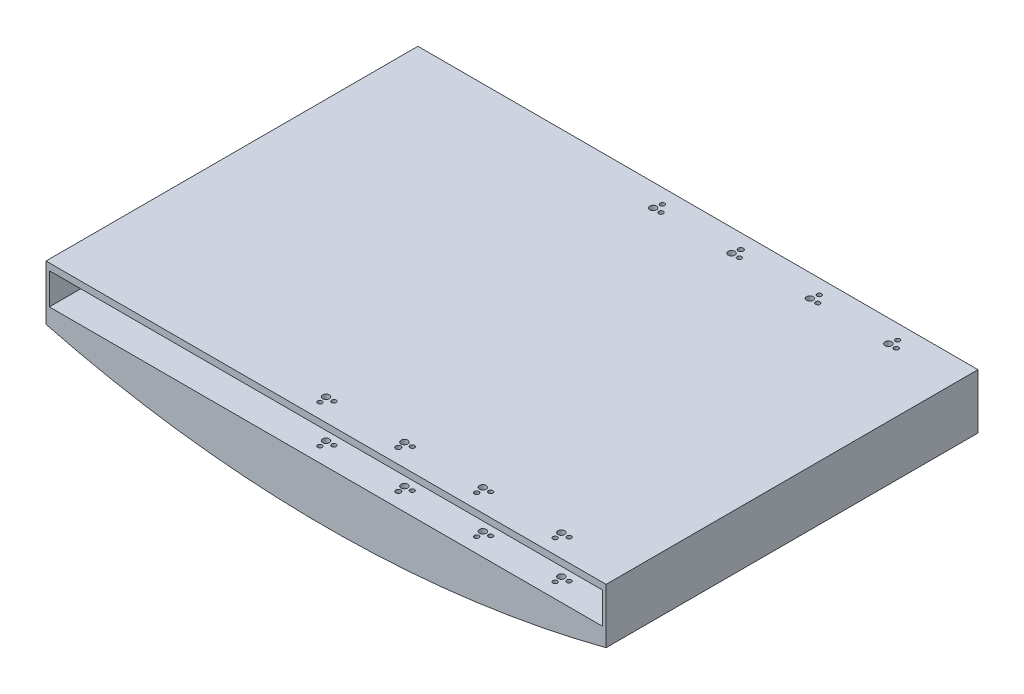
from build123d import *

# Parameters (mm, degrees)
SKETCH1_W               = 494
SKETCH1_H               = 33
BOSS_EXTRUDE2_DEPTH     = 166
SKETCH6_W               = 494
SKETCH6_H               = 32.558092213
CUT_EXTRUDE2_DEPTH      = 156
SKETCH8_W               = 494
SKETCH8_H               = 30
BOSS_EXTRUDE3_DEPTH     = 2.5
SKETCH9_W               = 494
SKETCH9_H               = 30
BOSS_EXTRUDE4_DEPTH     = 2.5
SKETCH10_W              = 494
SKETCH10_H              = 30
BOSS_EXTRUDE5_DEPTH     = 2.5
SKETCH11_W              = 494
SKETCH11_H              = 30
BOSS_EXTRUDE6_DEPTH     = 2.5
SKETCH7_R               = 3
SKETCH7_R_2             = 2
SKETCH7_R_3             = 2.270552225
CUT_EXTRUDE3_DEPTH      = 1
CUT_EXTRUDE3_DEPTH_BACK = 81.774674129


with BuildPart() as part:
    # Sketch1 → Boss-Extrude2 (new body, symmetric)
    with BuildSketch(Plane.XY):
        with BuildLine():
            Line((0, 0), (0, 49))
            Line((0, 49), (500, 49))
            Line((500, 49), (500, 0))
            ThreePointArc((500, 0), (250, -31.774674129), (0, 0))
        make_face()
        with Locations((250, 29)):
            Rectangle(SKETCH1_W, SKETCH1_H, mode=Mode.SUBTRACT)
    extrude(amount=BOSS_EXTRUDE2_DEPTH, both=True)

    # Sketch6 → Cut-Extrude2 (cut, symmetric)
    with BuildSketch(Plane.XY):
        with Locations((250, -16.279046107)):
            Rectangle(SKETCH6_W, SKETCH6_H)
    extrude(amount=CUT_EXTRUDE2_DEPTH, both=True, mode=Mode.SUBTRACT)

    # Sketch8 → Boss-Extrude3 (add)
    with BuildSketch(Plane(origin=(0, 12.5, 0), x_dir=(1, 0, 0), z_dir=(0, 1, 0))):
        with Locations((250, -151)):
            Rectangle(SKETCH8_W, SKETCH8_H)
    extrude(amount=BOSS_EXTRUDE3_DEPTH)

    # Sketch9 → Boss-Extrude4 (add)
    with BuildSketch(Plane.XZ.offset(-45.5)):
        with Locations((250, 151)):
            Rectangle(SKETCH9_W, SKETCH9_H)
    extrude(amount=BOSS_EXTRUDE4_DEPTH)

    # Sketch10 → Boss-Extrude5 (add)
    with BuildSketch(Plane.XZ.offset(-45.5)):
        with Locations((250, -151)):
            Rectangle(SKETCH10_W, SKETCH10_H)
    extrude(amount=BOSS_EXTRUDE5_DEPTH)

    # Sketch11 → Boss-Extrude6 (add)
    with BuildSketch(Plane(origin=(0, 12.5, 0), x_dir=(1, 0, 0), z_dir=(0, 1, 0))):
        with Locations((250, 151)):
            Rectangle(SKETCH11_W, SKETCH11_H)
    extrude(amount=BOSS_EXTRUDE6_DEPTH)

    # Sketch7 → Cut-Extrude3 (cut, two sides)
    with BuildSketch(Plane(origin=(0, 49, 0), x_dir=(1, 0, 0), z_dir=(0, 1, 0))) as cut_extrude3_sk:
        with Locations((230, -146)):
            Circle(SKETCH7_R)
        with Locations((300, -146)):
            Circle(SKETCH7_R)
        with Locations((370, -146)):
            Circle(SKETCH7_R)
        with Locations((440, -146)):
            Circle(SKETCH7_R)
        with Locations((231.366830489, -152.86525851)):
            Circle(SKETCH7_R_2)
        with Locations((301.366830489, -152.86525851)):
            Circle(SKETCH7_R_3)
        with Locations((371.366830489, -152.86525851)):
            Circle(SKETCH7_R_2)
        with Locations((441.366830489, -152.86525851)):
            Circle(SKETCH7_R_2)
        with Locations((237, -146)):
            Circle(SKETCH7_R_2)
        with Locations((307, -146)):
            Circle(SKETCH7_R_2)
        with Locations((377, -146)):
            Circle(SKETCH7_R_2)
        with Locations((447, -146)):
            Circle(SKETCH7_R_2)
        with Locations((440, 146)):
            Circle(SKETCH7_R)
        with Locations((370, 146)):
            Circle(SKETCH7_R)
        with Locations((300, 146)):
            Circle(SKETCH7_R)
        with Locations((230, 146)):
            Circle(SKETCH7_R)
        with Locations((441.366830489, 152.86525851)):
            Circle(SKETCH7_R_2)
        with Locations((447, 146)):
            Circle(SKETCH7_R_2)
        with Locations((371.366830489, 152.86525851)):
            Circle(SKETCH7_R_2)
        with Locations((377, 146)):
            Circle(SKETCH7_R_2)
        with Locations((307, 146)):
            Circle(SKETCH7_R_2)
        with Locations((301.366830489, 152.86525851)):
            Circle(SKETCH7_R_3)
        with Locations((237, 146)):
            Circle(SKETCH7_R_2)
        with Locations((231.366830489, 152.86525851)):
            Circle(SKETCH7_R_2)
    extrude(amount=CUT_EXTRUDE3_DEPTH, mode=Mode.SUBTRACT)
    extrude(cut_extrude3_sk.sketch, amount=-CUT_EXTRUDE3_DEPTH_BACK, mode=Mode.SUBTRACT)


solid = part.part
